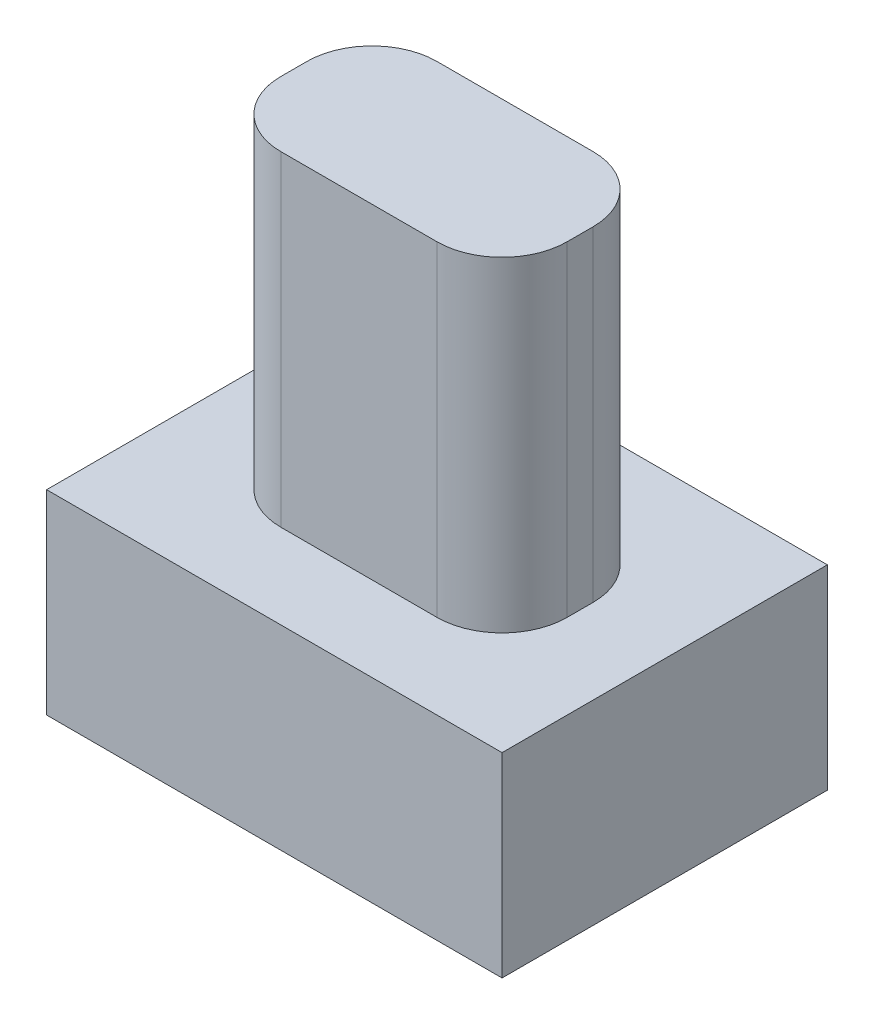
from build123d import *

# Parameters (mm, degrees)
SKETCH1_W           = 7
SKETCH1_H           = 5
BOSS_EXTRUDE1_DEPTH = 3
SKETCH2_W           = 4.4
SKETCH2_H           = 2.4
BOSS_EXTRUDE2_DEPTH = 5
FILLET1_R           = 1


with BuildPart() as part:
    # Sketch1 → Boss-Extrude1 (new body)
    with BuildSketch(Plane(origin=(0, 0, 0), x_dir=(1, 0, 0), z_dir=(0, 1, 0))):
        Rectangle(SKETCH1_W, SKETCH1_H)
    extrude(amount=BOSS_EXTRUDE1_DEPTH)

    # Sketch2 → Boss-Extrude2 (add)
    with BuildSketch(Plane(origin=(0, 3, 0), x_dir=(1, 0, 0), z_dir=(0, 1, 0))):
        Rectangle(SKETCH2_W, SKETCH2_H)
    extrude(amount=BOSS_EXTRUDE2_DEPTH)

    # Fillet1
    fillet1_edges = [part.edges().sort_by_distance(p)[0] for p in [
        (2.2, 5.5, 1.2),
        (2.2, 5.5, -1.2),
        (-2.2, 5.5, -1.2),
        (-2.2, 5.5, 1.2),
    ]]
    fillet(fillet1_edges, radius=FILLET1_R)


solid = part.part
